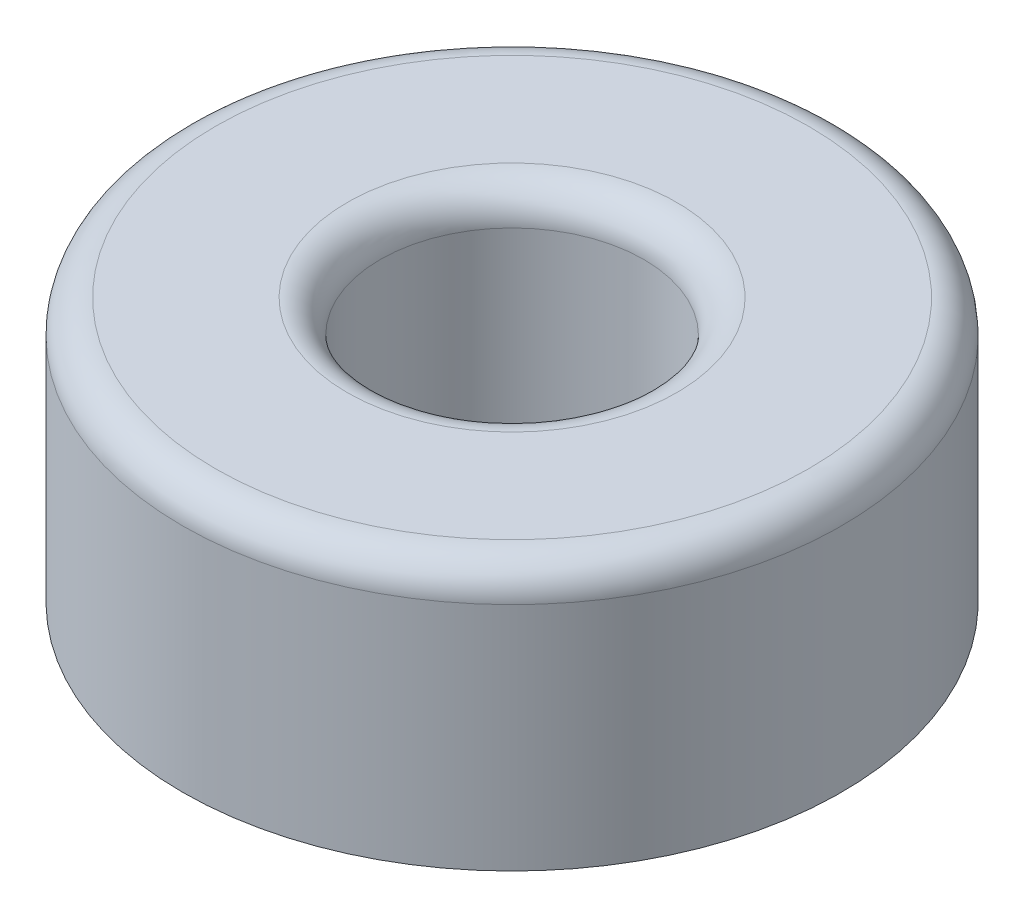
from build123d import *

# Parameters (mm, degrees)
SKETCH1_R           = 5
SKETCH1_R_2         = 2
BOSS_EXTRUDE1_DEPTH = 4
FILLET2_R           = 0.5


with BuildPart() as part:
    # Sketch1 → Boss-Extrude1 (new body)
    with BuildSketch(Plane(origin=(0, 0, 0), x_dir=(1, 0, 0), z_dir=(0, 1, 0))):
        Circle(SKETCH1_R)
        Circle(SKETCH1_R_2, mode=Mode.SUBTRACT)
    extrude(amount=BOSS_EXTRUDE1_DEPTH)

    # Fillet2
    fillet2_edges = [part.edges().sort_by_distance(p)[0] for p in [
        (-5, 4, 0),
        (-2, 4, 0),
    ]]
    fillet(fillet2_edges, radius=FILLET2_R)


solid = part.part
